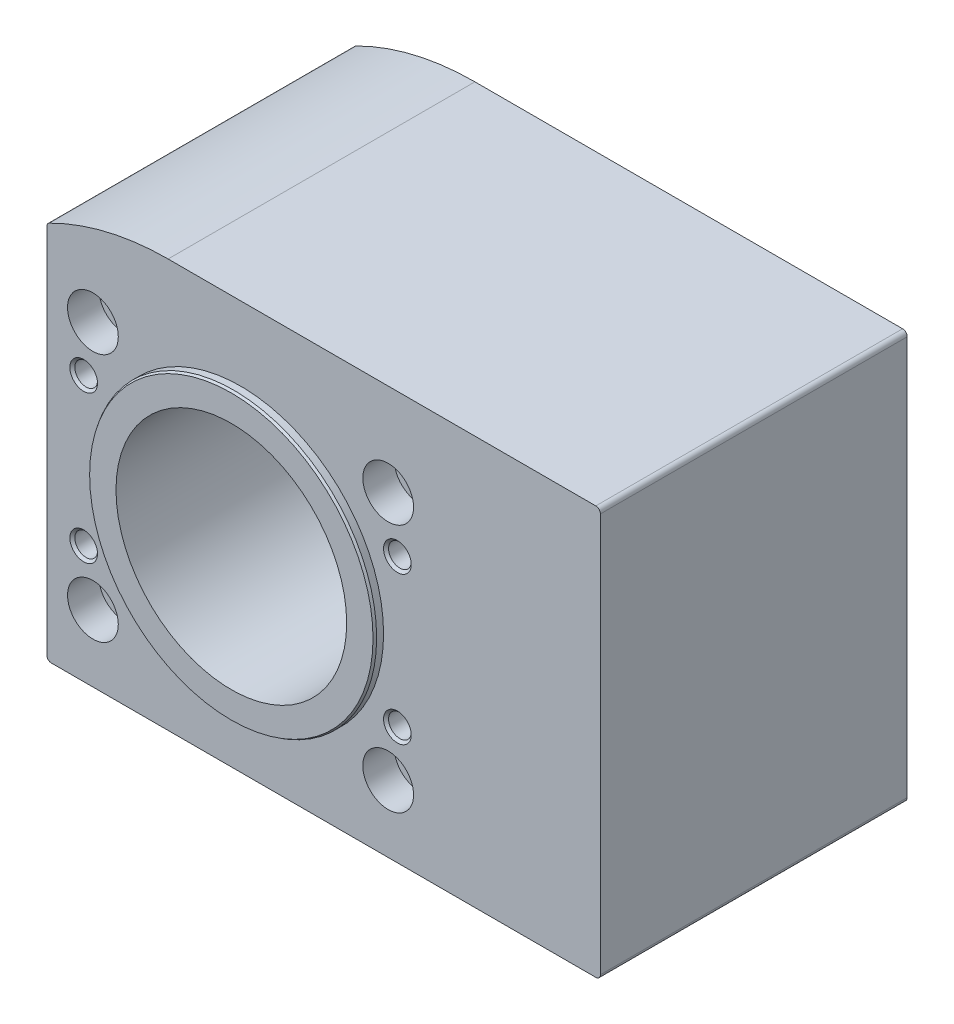
from build123d import *

# Parameters (mm, degrees)
LINEAR_AUSTRAGEN1_DEPTH = 66.5
SKIZZE3_R               = 25
LINEAR_AUSTRAGEN2_DEPTH = 70.5


with BuildPart() as part:
    # Skizze1 → Linear austragen1 (new body)
    with BuildSketch(Plane.XY):
        with BuildLine():
            Line((-42, 39.959083258), (-42, -40.5))
            ThreePointArc((-42, -40.5), (-41.707106781, -41.207106781), (-41, -41.5))
            Line((-41, -41.5), (77, -41.5))
            ThreePointArc((77, -41.5), (77.707106781, -41.207106781), (78, -40.5))
            Line((78, -40.5), (78, 46))
            ThreePointArc((78, 46), (77.707106781, 46.707106781), (77, 47))
            Line((77, 47), (-15.7, 47))
            ThreePointArc((-15.7, 47), (-28.937844321, 45.441495991), (-41.451785714, 40.851209745))
            ThreePointArc((-41.451785714, 40.851209745), (-41.851993461, 40.482635684), (-42, 39.959083258))
        make_face()
    extrude(amount=LINEAR_AUSTRAGEN1_DEPTH)

    # Skizze2 → Rotation1 (revolve)
    with BuildSketch(Plane(origin=(0, 0, 0), x_dir=(0, 0, -1), z_dir=(1, 0, 0))):
        Polygon((-68.5, 0), (-68.5, 30.711324865), (-68, 31), (1.5, 31), (2, 30.711324865), (2, 0), align=None)
    revolve(axis=Axis((0, 0, -2), (0, 0, 1)))

    # Skizze3 → Linear austragen2 (cut)
    with BuildSketch(Plane.XY.offset(-2)):
        Circle(SKIZZE3_R)
    extrude(amount=LINEAR_AUSTRAGEN2_DEPTH, mode=Mode.SUBTRACT)

    # Skizze4 → Schnitt-Rotation1 (revolve, cut)
    with BuildSketch(Plane(origin=(-32, 0, 0), x_dir=(0, 0, -1), z_dir=(1, 0, 0))):
        Polygon((-68.5, 27), (-68.5, 32.5), (-59.7, 32.5), (-59.7, 30.3), (-6.8, 30.3), (-6.8, 32.5), (2, 32.5), (2, 27), align=None)
    revolve(axis=Axis((-32, 27, -2), (0, 0, 1)), mode=Mode.SUBTRACT)

    # Skizze5 → Schnitt-Rotation2 (revolve, cut)
    with BuildSketch(Plane(origin=(-32, 0, 0), x_dir=(0, 0, -1), z_dir=(1, 0, 0))):
        Polygon((-68.5, -27), (-68.5, -21.5), (-59.7, -21.5), (-59.7, -23.7), (-6.8, -23.7), (-6.8, -21.5), (2, -21.5), (2, -27), align=None)
    revolve(axis=Axis((-32, -27, -2), (0, 0, 1)), mode=Mode.SUBTRACT)

    # Skizze6 → Schnitt-Rotation3 (revolve, cut)
    with BuildSketch(Plane(origin=(32, 0, 0), x_dir=(0, 0, -1), z_dir=(1, 0, 0))):
        Polygon((-68.5, -27), (-68.5, -21.5), (-59.7, -21.5), (-59.7, -23.7), (-6.8, -23.7), (-6.8, -21.5), (2, -21.5), (2, -27), align=None)
    revolve(axis=Axis((32, -27, -2), (0, 0, 1)), mode=Mode.SUBTRACT)

    # Skizze7 → Schnitt-Rotation4 (revolve, cut)
    with BuildSketch(Plane(origin=(32, 0, 0), x_dir=(0, 0, -1), z_dir=(1, 0, 0))):
        Polygon((-68.5, 27), (-68.5, 32.5), (-59.7, 32.5), (-59.7, 30.3), (-6.8, 30.3), (-6.8, 32.5), (2, 32.5), (2, 27), align=None)
    revolve(axis=Axis((32, 27, -2), (0, 0, 1)), mode=Mode.SUBTRACT)

    # Skizze8 → Schnitt-Rotation5 (revolve, cut)
    with BuildSketch(Plane(origin=(34, 0, 0), x_dir=(0, 0, -1), z_dir=(1, 0, 0))):
        Polygon((-18.519415637, 16), (-17.1, 18.4585), (-0.5415, 18.4585), (0, 19), (0, 16), align=None)
    revolve(axis=Axis((34, 16, 0), (0, 0, 1)), mode=Mode.SUBTRACT)

    # Skizze9 → Schnitt-Rotation6 (revolve, cut)
    with BuildSketch(Plane(origin=(34, 0, 0), x_dir=(0, 0, -1), z_dir=(1, 0, 0))):
        Polygon((-18.519415637, -16), (-17.1, -13.5415), (-0.5415, -13.5415), (0, -13), (0, -16), align=None)
    revolve(axis=Axis((34, -16, 0), (0, 0, 1)), mode=Mode.SUBTRACT)

    # Skizze10 → Schnitt-Rotation7 (revolve, cut)
    with BuildSketch(Plane(origin=(-34, 0, 0), x_dir=(0, 0, -1), z_dir=(1, 0, 0))):
        Polygon((-18.519415637, 16), (-17.1, 18.4585), (-0.5415, 18.4585), (0, 19), (0, 16), align=None)
    revolve(axis=Axis((-34, 16, 0), (0, 0, 1)), mode=Mode.SUBTRACT)

    # Skizze11 → Schnitt-Rotation8 (revolve, cut)
    with BuildSketch(Plane(origin=(-34, 0, 0), x_dir=(0, 0, -1), z_dir=(1, 0, 0))):
        Polygon((-18.519415637, -16), (-17.1, -13.5415), (-0.5415, -13.5415), (0, -13), (0, -16), align=None)
    revolve(axis=Axis((-34, -16, 0), (0, 0, 1)), mode=Mode.SUBTRACT)

    # Skizze12 → Schnitt-Rotation9 (revolve, cut)
    with BuildSketch(Plane(origin=(-34, 0, 0), x_dir=(0, 0, -1), z_dir=(1, 0, 0))):
        Polygon((-66.5, 16), (-66.5, 19), (-65.9585, 18.4585), (-49.4, 18.4585), (-47.980584363, 16), align=None)
    revolve(axis=Axis((-34, 16, 47.980584363), (0, 0, 1)), mode=Mode.SUBTRACT)

    # Skizze13 → Schnitt-Rotation10 (revolve, cut)
    with BuildSketch(Plane(origin=(-34, 0, 0), x_dir=(0, 0, -1), z_dir=(1, 0, 0))):
        Polygon((-66.5, -16), (-66.5, -13), (-65.9585, -13.5415), (-49.4, -13.5415), (-47.980584363, -16), align=None)
    revolve(axis=Axis((-34, -16, 47.980584363), (0, 0, 1)), mode=Mode.SUBTRACT)

    # Skizze14 → Schnitt-Rotation11 (revolve, cut)
    with BuildSketch(Plane(origin=(34, 0, 0), x_dir=(0, 0, -1), z_dir=(1, 0, 0))):
        Polygon((-66.5, 16), (-66.5, 19), (-65.9585, 18.4585), (-49.4, 18.4585), (-47.980584363, 16), align=None)
    revolve(axis=Axis((34, 16, 47.980584363), (0, 0, 1)), mode=Mode.SUBTRACT)

    # Skizze15 → Schnitt-Rotation12 (revolve, cut)
    with BuildSketch(Plane(origin=(34, 0, 0), x_dir=(0, 0, -1), z_dir=(1, 0, 0))):
        Polygon((-66.5, -16), (-66.5, -13), (-65.9585, -13.5415), (-49.4, -13.5415), (-47.980584363, -16), align=None)
    revolve(axis=Axis((34, -16, 47.980584363), (0, 0, 1)), mode=Mode.SUBTRACT)


solid = part.part
